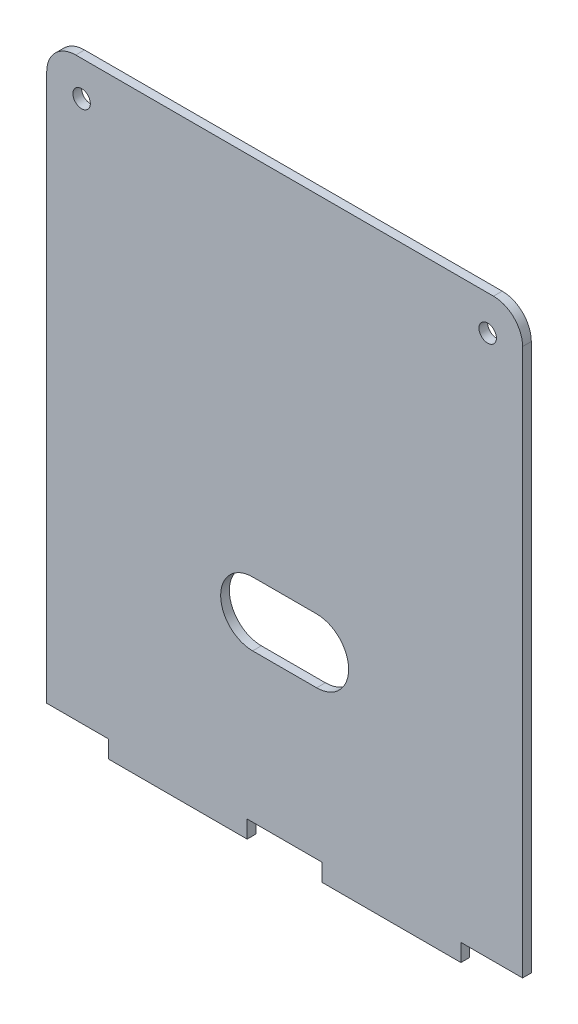
from build123d import *

# Parameters (mm, degrees)
SKETCH1_W           = 81.8
SKETCH1_H           = 102
BOSS_EXTRUDE1_DEPTH = 1.5
SKETCH2_W           = 10.6
SKETCH2_H           = 3
SKETCH2_W_2         = 6.445
SKETCH2_R           = 1.5
CUT_EXTRUDE1_DEPTH  = 2.5
CUT_EXTRUDE2_DEPTH  = 2.5
FILLET1_R           = 5


with BuildPart() as part:
    # Sketch1 → Boss-Extrude1 (new body)
    with BuildSketch(Plane.XY):
        with Locations((40.9, 51)):
            Rectangle(SKETCH1_W, SKETCH1_H)
    extrude(amount=BOSS_EXTRUDE1_DEPTH)

    # Sketch2 → Cut-Extrude1 (cut, through all)
    with BuildSketch(Plane.XY.offset(1.5)):
        with Locations((5.3, 1.5)):
            Rectangle(SKETCH2_W, SKETCH2_H)
        with Locations((44.1225, 1.5)):
            Rectangle(SKETCH2_W_2, SKETCH2_H)
        with Locations((37.6775, 1.5)):
            Rectangle(SKETCH2_W_2, SKETCH2_H)
        with Locations((76.5, 1.5)):
            Rectangle(SKETCH2_W, SKETCH2_H)
        with Locations((6, 96)):
            Circle(SKETCH2_R)
        with Locations((75.8, 96)):
            Circle(SKETCH2_R)
    extrude(amount=-CUT_EXTRUDE1_DEPTH, mode=Mode.SUBTRACT)

    # Sketch3 → Cut-Extrude2 (cut, through all)
    with BuildSketch(Plane.XY.offset(1.5)):
        with BuildLine():
            ThreePointArc((35.4, 28.5), (39.289087297, 30.110912703), (40.9, 34))
            Line((40.9, 34), (29.9, 34))
            ThreePointArc((29.9, 34), (31.510912703, 30.110912703), (35.4, 28.5))
        make_face()
        with BuildLine():
            Line((29.9, 34), (40.9, 34))
            ThreePointArc((40.9, 34), (39.289087297, 37.889087297), (35.4, 39.5))
            ThreePointArc((35.4, 39.5), (31.510912703, 37.889087297), (29.9, 34))
        make_face()
        with BuildLine():
            ThreePointArc((46.4, 39.5), (42.510912703, 37.889087297), (40.9, 34))
            Line((40.9, 34), (51.9, 34))
            ThreePointArc((51.9, 34), (50.289087297, 37.889087297), (46.4, 39.5))
        make_face()
        with BuildLine():
            Line((51.9, 34), (40.9, 34))
            ThreePointArc((40.9, 34), (42.510912703, 30.110912703), (46.4, 28.5))
            ThreePointArc((46.4, 28.5), (50.289087297, 30.110912703), (51.9, 34))
        make_face()
        with BuildLine():
            Line((40.9, 28.5), (40.9, 34))
            ThreePointArc((40.9, 34), (39.289087297, 30.110912703), (35.4, 28.5))
            Line((35.4, 28.5), (40.9, 28.5))
        make_face()
        with BuildLine():
            ThreePointArc((46.4, 28.5), (42.510912703, 30.110912703), (40.9, 34))
            Line((40.9, 34), (40.9, 28.5))
            Line((40.9, 28.5), (46.4, 28.5))
        make_face()
        with BuildLine():
            Line((40.9, 39.5), (40.9, 34))
            ThreePointArc((40.9, 34), (42.510912703, 37.889087297), (46.4, 39.5))
            Line((46.4, 39.5), (40.9, 39.5))
        make_face()
        with BuildLine():
            ThreePointArc((35.4, 39.5), (39.289087297, 37.889087297), (40.9, 34))
            Line((40.9, 34), (40.9, 39.5))
            Line((40.9, 39.5), (35.4, 39.5))
        make_face()
    extrude(amount=-CUT_EXTRUDE2_DEPTH, mode=Mode.SUBTRACT)

    # Fillet1
    fillet1_edges = [part.edges().sort_by_distance(p)[0] for p in [
        (0, 102, 0.75),
        (81.8, 102, 0.75),
    ]]
    fillet(fillet1_edges, radius=FILLET1_R)


solid = part.part
